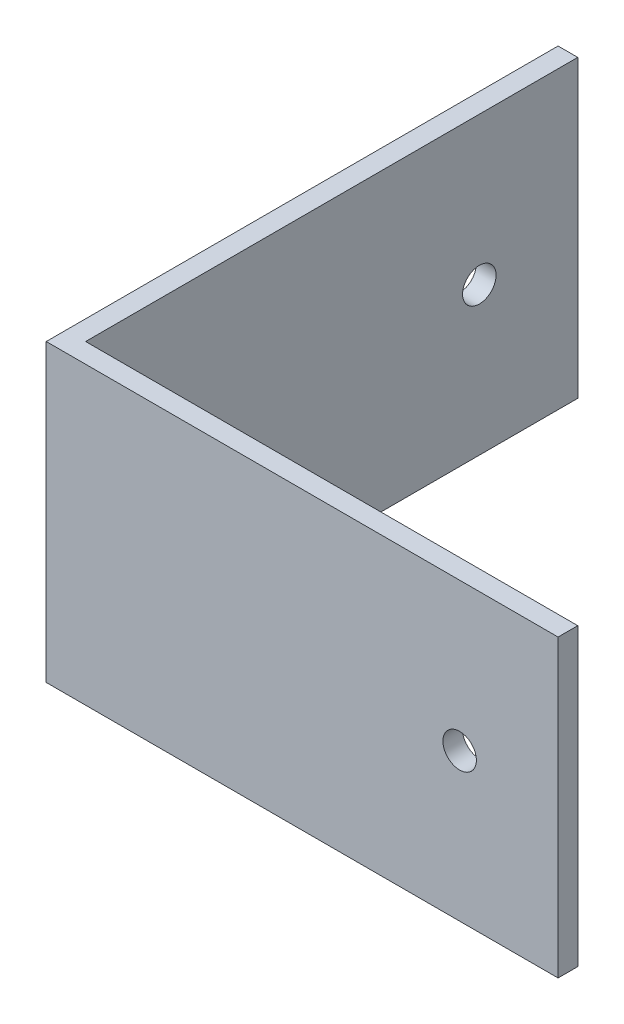
from build123d import *

# Parameters (mm, degrees)
SKETCH1_W           = 25
SKETCH1_H           = 15
SKETCH1_R           = 0.85
BOSS_EXTRUDE1_DEPTH = 1
SKETCH2_W           = 26
SKETCH2_H           = 15
SKETCH2_R           = 0.85
BOSS_EXTRUDE2_DEPTH = 1


with BuildPart() as part:
    # Sketch1 → Boss-Extrude1 (new body)
    with BuildSketch(Plane.XY):
        Rectangle(SKETCH1_W, SKETCH1_H)
        with Locations((7.5, 0)):
            Circle(SKETCH1_R, mode=Mode.SUBTRACT)
    extrude(amount=BOSS_EXTRUDE1_DEPTH)

    # Sketch2 → Boss-Extrude2 (add)
    with BuildSketch(Plane.ZY.offset(12.5)):
        with Locations((-12, 0)):
            Rectangle(SKETCH2_W, SKETCH2_H)
        with Locations((-20, 0)):
            Circle(SKETCH2_R, mode=Mode.SUBTRACT)
    extrude(amount=BOSS_EXTRUDE2_DEPTH)


solid = part.part
